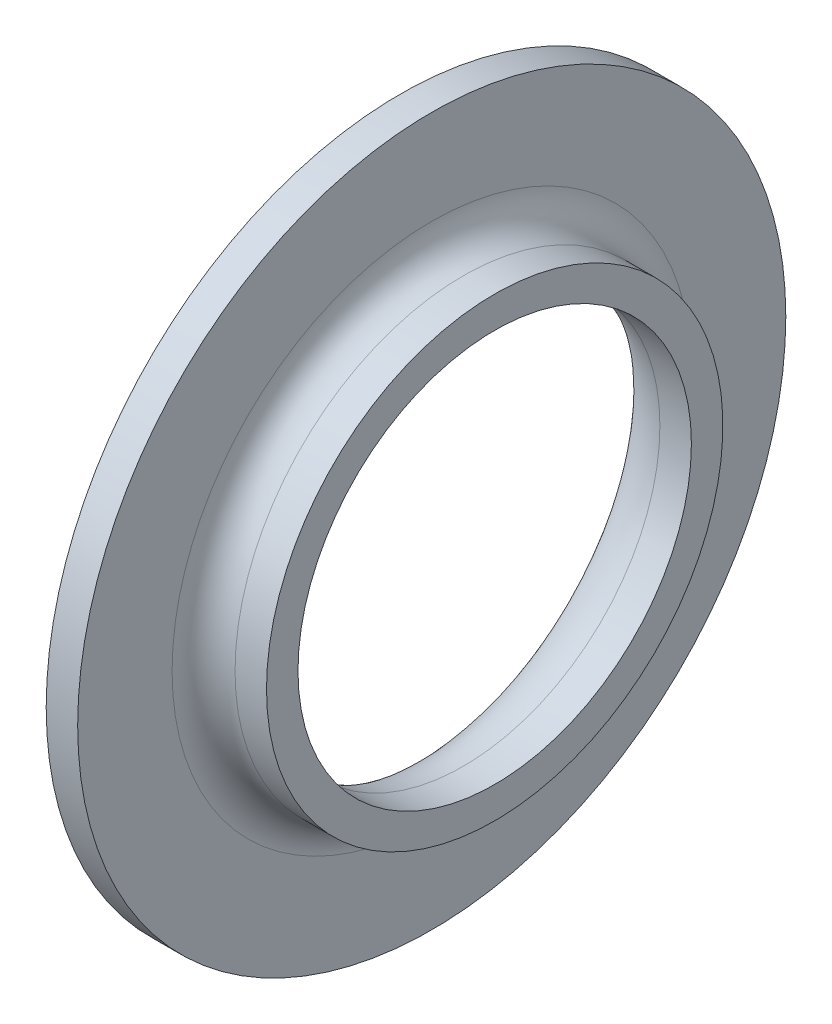
from build123d import *


with BuildPart() as part:
    # Sketch1 → Revolve1 (revolve)
    with BuildSketch(Plane.XY):
        with BuildLine():
            Line((0, 45), (4, 45))
            Line((4, 45), (4, 33))
            ThreePointArc((4, 33), (5.171572875, 30.171572875), (8, 29))
            Line((8, 29), (12, 29))
            Line((12, 29), (12, 25))
            Line((12, 25), (8, 25))
            ThreePointArc((8, 25), (2.343145751, 27.343145751), (0, 33))
            Line((0, 33), (0, 45))
        make_face()
    revolve(axis=Axis((0, 0, 0), (1, 0, 0)))


solid = part.part
